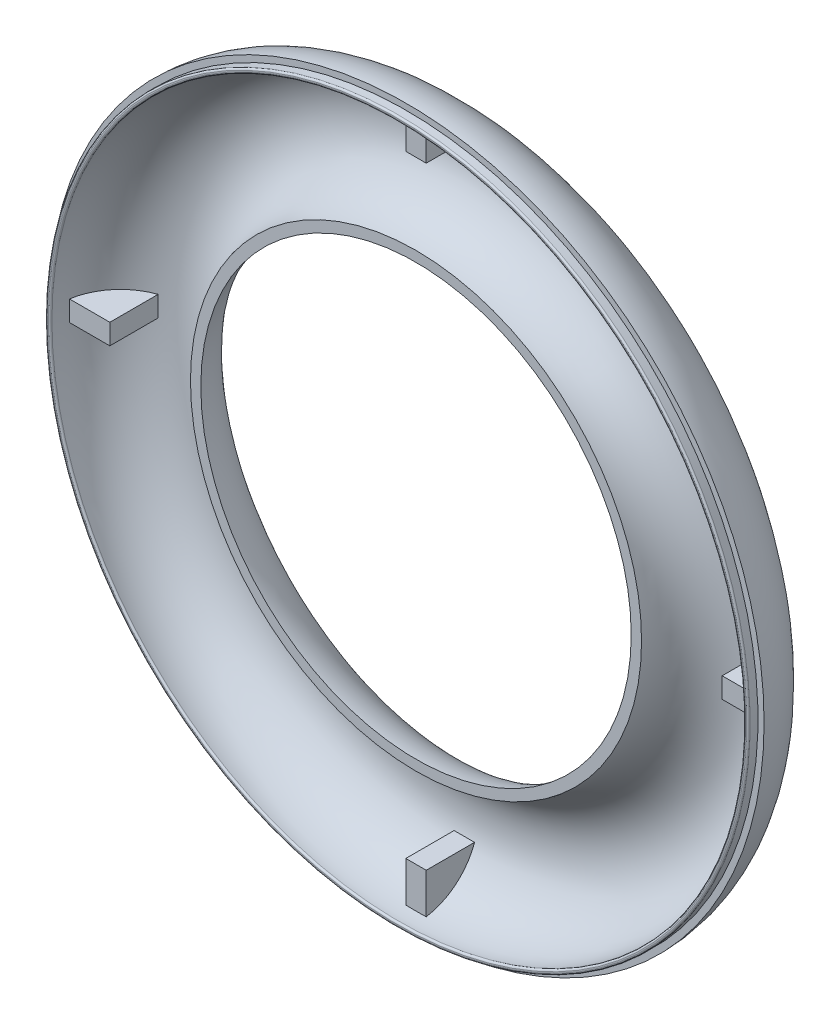
from build123d import *

# Parameters (mm, degrees)
LEDGE_REACH      = 78.385
LEDGE_START      = -1.4
LEDGE_SKETCH_W   = 6
LEDGE_SKETCH_H   = 3
LEDGE_SKETCH_W_2 = 3
LEDGE_SKETCH_H_2 = 6
LIP_FILLET_R     = 0.25


with BuildPart() as part:
    # Main Belt: sweep along a path in Belt Path
    with BuildLine(Plane.XY) as main_belt_path:
        CenterArc((0, 0), 42, 0, 360)
    # Belt Profile → Main Belt (sweep)
    with BuildSketch(Plane(origin=(0, 0, 0), x_dir=(1, 0, 0), z_dir=(0, 1, 0))):
        with BuildLine():
            Line((-52.5, 0), (-51.6, 0))
            Line((-51.6, 0), (-51.6, -1.4))
            Line((-51.6, -1.4), (-50.890444308, -1.4))
            ThreePointArc((-50.890444308, -1.4), (-43.4, 8.890444308), (-33.109555692, 1.4))
            Line((-33.109555692, 1.4), (-31.593751877, 1.4))
            ThreePointArc((-31.593751877, 1.4), (-42.701567783, 10.476535813), (-52.5, 0))
        make_face()
    sweep(path=main_belt_path.line)

    # Ledge Sketch → Ledge (add, up to next)
    with BuildSketch(Plane.XY.offset(LEDGE_START), mode=Mode.PRIVATE) as ledge_sk1:
        with Locations((-47.94427191, 0)):
            Rectangle(LEDGE_SKETCH_W, LEDGE_SKETCH_H)
    ledge_tool1 = extrude(ledge_sk1.sketch, amount=-LEDGE_REACH, mode=Mode.PRIVATE) - part.part
    # Ledge Sketch → Ledge (add, up to next)
    with BuildSketch(Plane.XY.offset(LEDGE_START), mode=Mode.PRIVATE) as ledge_sk2:
        with Locations((0, 47.94427191)):
            Rectangle(LEDGE_SKETCH_W_2, LEDGE_SKETCH_H_2)
    ledge_tool2 = extrude(ledge_sk2.sketch, amount=-LEDGE_REACH, mode=Mode.PRIVATE) - part.part
    # Ledge Sketch → Ledge (add, up to next)
    with BuildSketch(Plane.XY.offset(LEDGE_START), mode=Mode.PRIVATE) as ledge_sk3:
        with Locations((47.94427191, 0)):
            Rectangle(LEDGE_SKETCH_W, LEDGE_SKETCH_H)
    ledge_tool3 = extrude(ledge_sk3.sketch, amount=-LEDGE_REACH, mode=Mode.PRIVATE) - part.part
    # Ledge Sketch → Ledge (add, up to next)
    with BuildSketch(Plane.XY.offset(LEDGE_START), mode=Mode.PRIVATE) as ledge_sk4:
        with Locations((0, -47.94427191)):
            Rectangle(LEDGE_SKETCH_W_2, LEDGE_SKETCH_H_2)
    ledge_tool4 = extrude(ledge_sk4.sketch, amount=-LEDGE_REACH, mode=Mode.PRIVATE) - part.part
    add(ledge_tool1.solids().sort_by_distance((-47.944272, 0, -1.4))[0])
    add(ledge_tool2.solids().sort_by_distance((0, 47.944272, -1.4))[0])
    add(ledge_tool3.solids().sort_by_distance((47.944272, 0, -1.4))[0])
    add(ledge_tool4.solids().sort_by_distance((0, -47.944272, -1.4))[0])

    # Lip Fillet
    lip_fillet_edges = [part.edges().sort_by_distance(p)[0] for p in [
        (-51.6, 0, 1.4),
        (-50.890444308, 0, 1.4),
    ]]
    fillet(lip_fillet_edges, radius=LIP_FILLET_R)


solid = part.part
